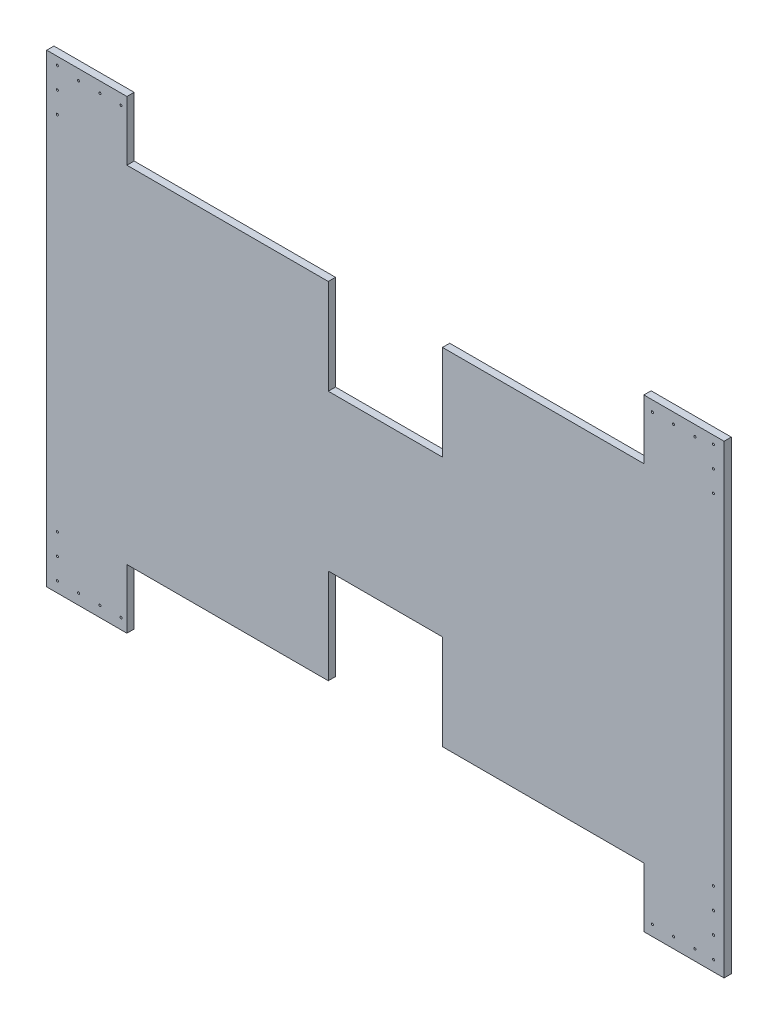
from build123d import *

# Parameters (mm, degrees)
SKETCH1_W           = 809.625
SKETCH1_H           = 555.625
SKETCH1_R           = 1.27
BOSS_EXTRUDE1_DEPTH = 4.318
CUT_EXTRUDE2_DEPTH  = 491.990417866


with BuildPart() as part:
    # Sketch1 → Boss-Extrude1 (new, symmetric)
    with BuildSketch(Plane.XY):
        Rectangle(SKETCH1_W, SKETCH1_H)
        with Locations((-392.1125, -265.1125)):
            Circle(SKETCH1_R, mode=Mode.SUBTRACT)
        with Locations((-366.7125, -265.1125)):
            Circle(SKETCH1_R, mode=Mode.SUBTRACT)
        with Locations((-341.3125, -265.1125)):
            Circle(SKETCH1_R, mode=Mode.SUBTRACT)
        with Locations((-315.9125, -265.1125)):
            Circle(SKETCH1_R, mode=Mode.SUBTRACT)
        with Locations((-392.1125, -239.7125)):
            Circle(SKETCH1_R, mode=Mode.SUBTRACT)
        with Locations((-392.1125, -214.3125)):
            Circle(SKETCH1_R, mode=Mode.SUBTRACT)
        with Locations((319.0875, -265.1125)):
            Circle(SKETCH1_R, mode=Mode.SUBTRACT)
        with Locations((344.4875, -265.1125)):
            Circle(SKETCH1_R, mode=Mode.SUBTRACT)
        with Locations((369.8875, -265.1125)):
            Circle(SKETCH1_R, mode=Mode.SUBTRACT)
        with Locations((392.1125, -265.1125)):
            Circle(SKETCH1_R, mode=Mode.SUBTRACT)
        with Locations((392.1125, -239.7125)):
            Circle(SKETCH1_R, mode=Mode.SUBTRACT)
        with Locations((392.1125, -214.3125)):
            Circle(SKETCH1_R, mode=Mode.SUBTRACT)
        with Locations((392.1125, -188.9125)):
            Circle(SKETCH1_R, mode=Mode.SUBTRACT)
        with Locations((392.1125, 268.2875)):
            Circle(SKETCH1_R, mode=Mode.SUBTRACT)
        with Locations((-392.1125, 217.4875)):
            Circle(SKETCH1_R, mode=Mode.SUBTRACT)
        with Locations((-392.1125, 242.8875)):
            Circle(SKETCH1_R, mode=Mode.SUBTRACT)
        with Locations((-392.1125, 268.2875)):
            Circle(SKETCH1_R, mode=Mode.SUBTRACT)
        with Locations((-366.7125, 265.1125)):
            Circle(SKETCH1_R, mode=Mode.SUBTRACT)
        with Locations((-341.3125, 265.1125)):
            Circle(SKETCH1_R, mode=Mode.SUBTRACT)
        with Locations((-315.9125, 265.1125)):
            Circle(SKETCH1_R, mode=Mode.SUBTRACT)
        with Locations((392.1125, 217.4875)):
            Circle(SKETCH1_R, mode=Mode.SUBTRACT)
        with Locations((392.1125, 242.8875)):
            Circle(SKETCH1_R, mode=Mode.SUBTRACT)
        with Locations((319.0875, 265.1125)):
            Circle(SKETCH1_R, mode=Mode.SUBTRACT)
        with Locations((344.4875, 265.1125)):
            Circle(SKETCH1_R, mode=Mode.SUBTRACT)
        with Locations((369.8875, 265.1125)):
            Circle(SKETCH1_R, mode=Mode.SUBTRACT)
    extrude(amount=BOSS_EXTRUDE1_DEPTH, both=True)

    # Sketch1_3 → Cut-Extrude2 (cut, symmetric)
    with BuildSketch(Plane.XY):
        Polygon((-308.956687333, -206.6798), (-308.956687333, -277.8125), (308.956687333, -277.8125), (308.956687333, -206.68615), (68.2625, -206.68615), (68.2625, -93.05192559), (-68.2625, -93.05192559), (-68.2625, -206.6798), align=None)
    cut_extrude2 = extrude(amount=CUT_EXTRUDE2_DEPTH, both=True, mode=Mode.SUBTRACT)

    # Mirror1: Cut-Extrude2 across plane
    add(cut_extrude2.mirror(Plane.ZX), mode=Mode.SUBTRACT)


solid = part.part
